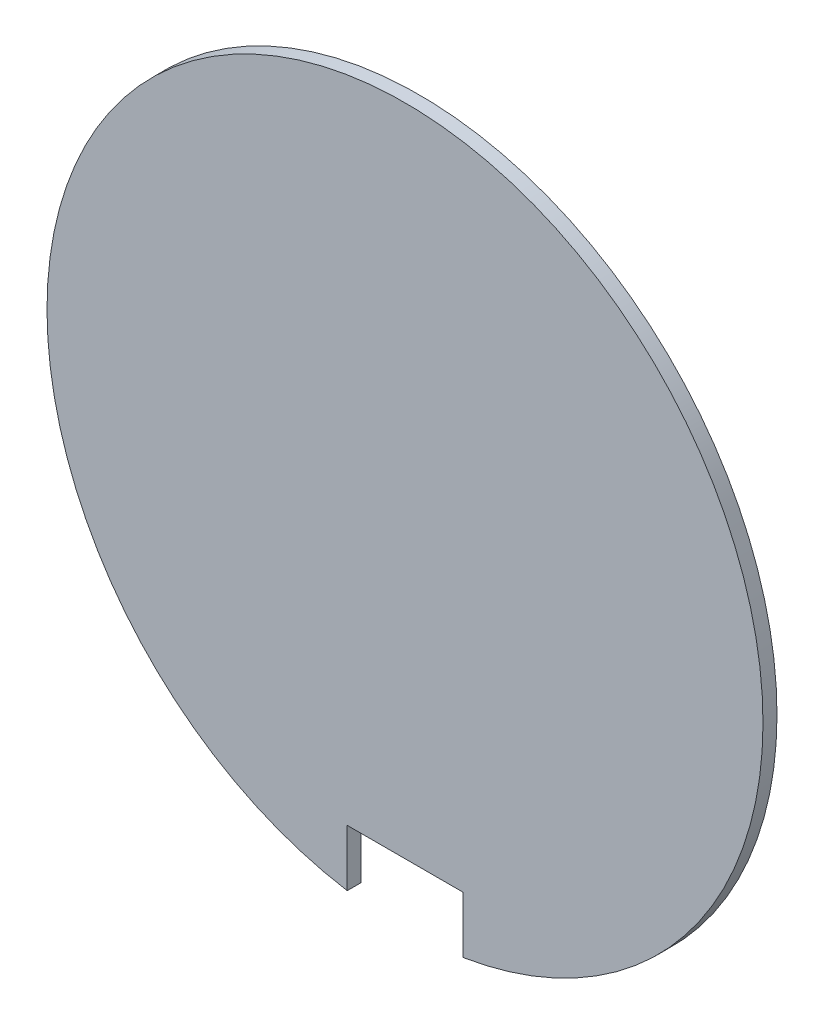
from build123d import *

# Parameters (mm, degrees)
BASE_EXTRUDE_DEPTH = 0.4064


with BuildPart() as part:
    # Sketch1 → Base-Extrude (new body)
    with BuildSketch(Plane.XY):
        with BuildLine():
            Line((1.6764, -10.252448147), (1.6764, -8.6106))
            Line((1.6764, -8.6106), (-1.6764, -8.6106))
            Line((-1.6764, -8.6106), (-1.6764, -10.252448147))
            ThreePointArc((-1.6764, -10.252448147), (0, 10.3886), (1.6764, -10.252448147))
        make_face()
    extrude(amount=BASE_EXTRUDE_DEPTH)


solid = part.part
